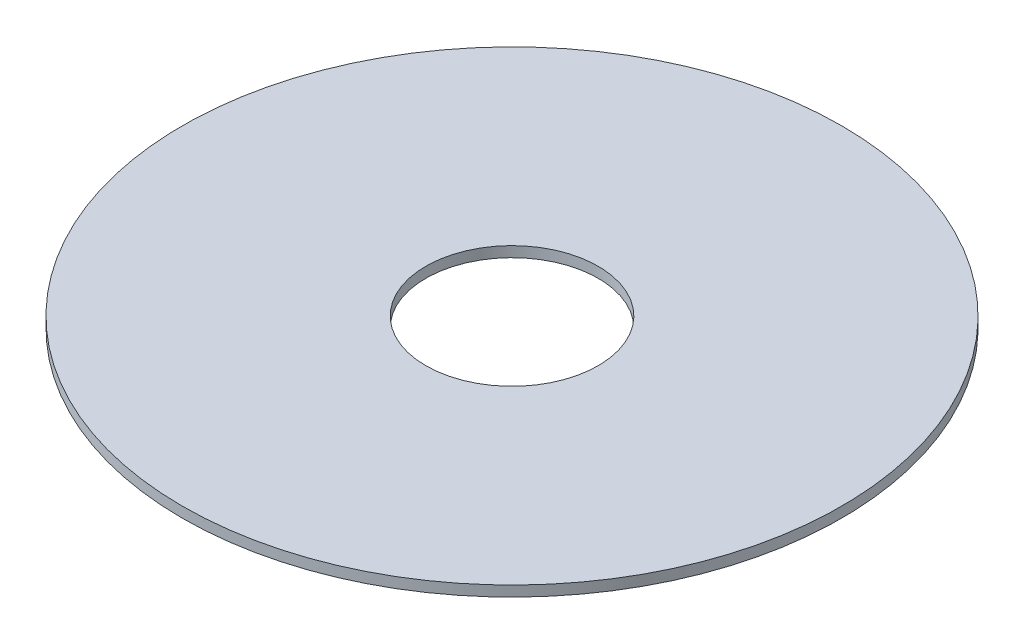
from build123d import *

# Parameters (mm, degrees)
SKETCH1_R           = 53.5344
SKETCH1_R_2         = 14
BOSS_EXTRUDE1_DEPTH = 1.7


with BuildPart() as part:
    # Sketch1 → Boss-Extrude1 (new body)
    with BuildSketch(Plane(origin=(0, 0, 0), x_dir=(1, 0, 0), z_dir=(0, 1, 0))):
        Circle(SKETCH1_R)
        Circle(SKETCH1_R_2, mode=Mode.SUBTRACT)
    extrude(amount=BOSS_EXTRUDE1_DEPTH)


solid = part.part
